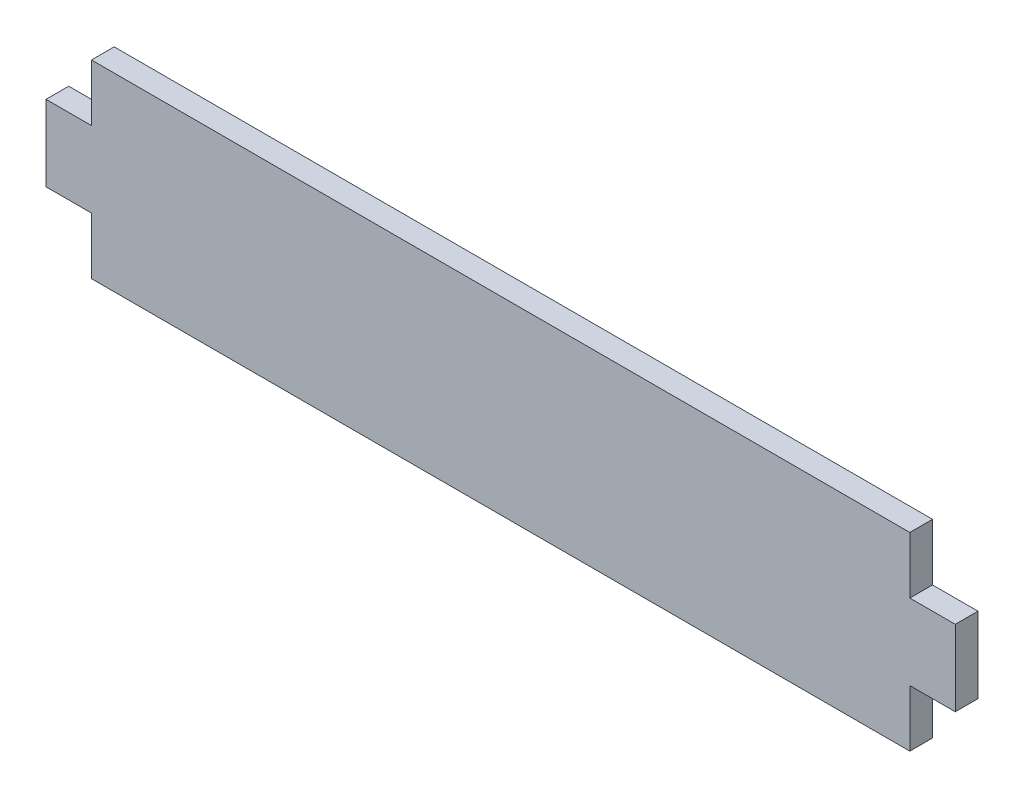
from build123d import *

# Parameters (mm, degrees)
BOSS_EXTRUDE1_DEPTH = 3


with BuildPart() as part:
    # Sketch1 → Boss-Extrude1 (new body)
    with BuildSketch(Plane.XY):
        Polygon((54, 12.5), (-54, 12.5), (-54, 5), (-60, 5), (-60, -5), (-54, -5), (-54, -12.5), (54, -12.5), (54, -5), (60, -5), (60, 5), (54, 5), align=None)
    extrude(amount=BOSS_EXTRUDE1_DEPTH)


solid = part.part
